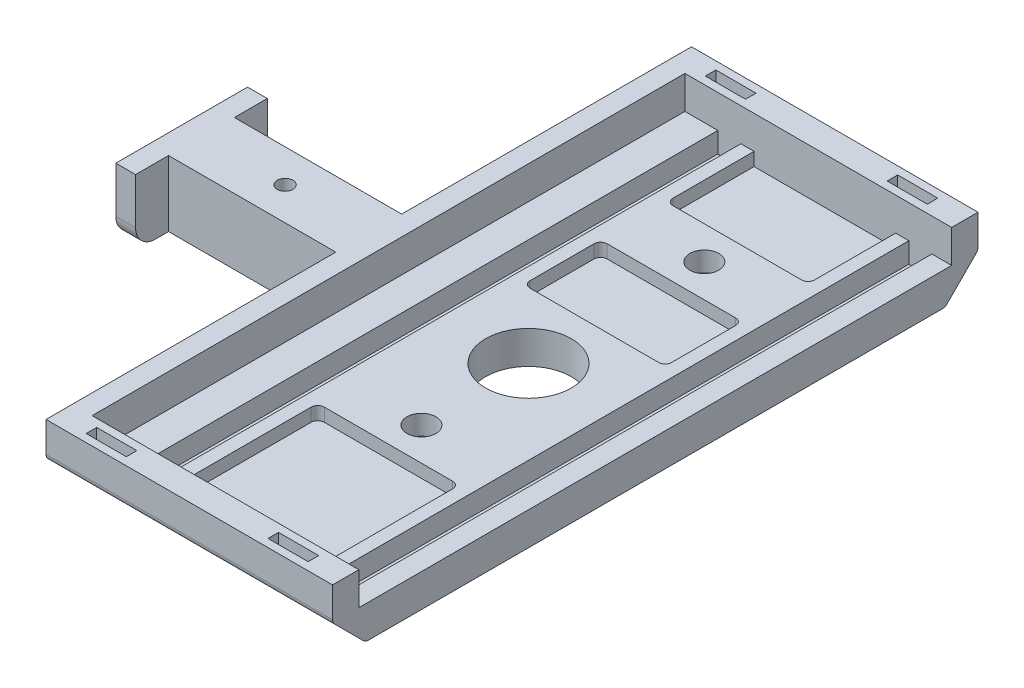
from build123d import *

# Parameters (mm, degrees)
BOSS_EXTRUDE1_DEPTH            = 45
SKETCH3_R                      = 6.5
CUT_EXTRUDE1_DEPTH             = 50.199212392
SKETCH5_W                      = 5
SKETCH5_H                      = 10
BOSS_EXTRUDE2_DEPTH            = 45
BOSS_EXTRUDE2_DEPTH_BACK       = 45
SKETCH8_W                      = 43.5
SKETCH8_H                      = 10
BOSS_EXTRUDE3_DEPTH            = 3
MOVE_FACE1_BY                  = 1
MOVE_FACE2_BY                  = 1
SKETCH10_W                     = 6.1
SKETCH10_H                     = 1.6
CUT_EXTRUDE2_DEPTH             = 3.5
CBORE_FOR_M2_SHCS1_D           = 2.4
CBORE_FOR_M2_SHCS1_CBORE_D     = 4.4
CBORE_FOR_M2_SHCS1_CBORE_DEPTH = 3
SKETCH12_W                     = 10
SKETCH12_H                     = 10
BOSS_EXTRUDE4_DEPTH            = 25.4
SKETCH13_W                     = 3
SKETCH13_H                     = 10
BOSS_EXTRUDE5_DEPTH            = 10
FILLET1_R                      = 3
CHAMFER1_SIZE                  = 5
FILLET2_R                      = 1
MOVE_FACE3_BY                  = 2
M2_CLEARANCE_HOLE1_D           = 2.4
SKETCH18_W                     = 21.5
SKETCH18_H                     = 23.75
SKETCH18_H_2                   = 11.7
SKETCH18_H_3                   = 13.3
CUT_EXTRUDE4_DEPTH             = 2
FILLET4_R                      = 1


with BuildPart() as part:
    # Sketch2 → Boss-Extrude1 (new, symmetric)
    with BuildSketch(Plane.XY):
        Polygon((-19.25, 0), (19.25, 0), (19.25, 5), (16.25, 5), (16.25, 1.9), (12.75, 1.9), (12.75, 5), (-12.75, 5), (-12.75, 1.9), (-16.25, 1.9), (-16.25, 5), (-19.25, 5), align=None)
    extrude(amount=BOSS_EXTRUDE1_DEPTH, both=True)

    # Sketch3 → Cut-Extrude1 (cut, through all)
    with BuildSketch(Plane.XZ):
        with Locations(Location((0, 0, 0), (0, 0, 270))):
            Circle(SKETCH3_R)
    extrude(amount=-CUT_EXTRUDE1_DEPTH, mode=Mode.SUBTRACT)

    # Sketch5 → Boss-Extrude2 (add, two sides)
    with BuildSketch(Plane.XY) as boss_extrude2_sk:
        with Locations((-21.75, 5)):
            Rectangle(SKETCH5_W, SKETCH5_H)
    extrude(amount=BOSS_EXTRUDE2_DEPTH)
    extrude(boss_extrude2_sk.sketch, amount=-BOSS_EXTRUDE2_DEPTH_BACK)

    # Sketch8 → Boss-Extrude3 (add)
    with BuildSketch(Plane.XY.offset(45)):
        with Locations((-2.5, 5)):
            Rectangle(SKETCH8_W, SKETCH8_H)
    boss_extrude3 = extrude(amount=BOSS_EXTRUDE3_DEPTH)

    # Mirror1: Boss-Extrude3 across plane
    add(boss_extrude3.mirror(Plane.XY))

    # Move Face1: a face moved outward by 1.0
    extrude(part.faces().sort_by_distance((-2.5, 5, -48))[0], amount=MOVE_FACE1_BY, dir=(0, 0, -1))

    # Move Face2: a face moved outward by 1.0
    extrude(part.faces().sort_by_distance((-2.5, 5, 48))[0], amount=MOVE_FACE2_BY, dir=(0, 0, 1))

    # Sketch10 → Cut-Extrude2 (cut)
    with BuildSketch(Plane(origin=(0, 10, 0), x_dir=(1, 0, 0), z_dir=(0, 1, 0))):
        with Locations((-16.3, 47)):
            Rectangle(SKETCH10_W, SKETCH10_H)
        with Locations((11.3, 47)):
            Rectangle(SKETCH10_W, SKETCH10_H)
        with Locations((-16.3, -47)):
            Rectangle(SKETCH10_W, SKETCH10_H)
        with Locations((11.3, -47)):
            Rectangle(SKETCH10_W, SKETCH10_H)
    extrude(amount=-CUT_EXTRUDE2_DEPTH, mode=Mode.SUBTRACT)

    # CBORE for M2 SHCS1 (through all)
    with Locations(Plane(origin=(0, 5, 0), x_dir=(1, 0, 0), z_dir=(0, 1, 0))):
        with Locations((0, 26.7), (0, -16.25)):
            CounterBoreHole(CBORE_FOR_M2_SHCS1_D / 2, CBORE_FOR_M2_SHCS1_CBORE_D / 2, CBORE_FOR_M2_SHCS1_CBORE_DEPTH)

    # Sketch12 → Boss-Extrude4 (add)
    with BuildSketch(Plane.ZY.offset(24.25)):
        with Locations((0, 5)):
            Rectangle(SKETCH12_W, SKETCH12_H)
    extrude(amount=BOSS_EXTRUDE4_DEPTH)

    # Sketch13 → Boss-Extrude5 (add, symmetric)
    with BuildSketch(Plane.XY):
        with Locations((-51.15, 5)):
            Rectangle(SKETCH13_W, SKETCH13_H)
    extrude(amount=BOSS_EXTRUDE5_DEPTH, both=True)

    # Fillet1
    fillet1_edges = [part.edges().sort_by_distance(p)[0] for p in [
        (-51.15, 0, -10),
        (-51.15, 0, 10),
    ]]
    fillet(fillet1_edges, radius=FILLET1_R)

    # Chamfer1
    chamfer1_edges = [part.edges().sort_by_distance(p)[0] for p in [
        (-2.5, 0, 49),
        (-2.5, 0, -49),
    ]]
    chamfer(chamfer1_edges, length=CHAMFER1_SIZE)

    # Fillet2
    fillet2_edges = [part.edges().sort_by_distance(p)[0] for p in [
        (-2.5, 0, 44),
        (-2.5, 0, -44),
        (-2.5, 5, -49),
        (-2.5, 5, 49),
    ]]
    fillet(fillet2_edges, radius=FILLET2_R)

    # Move Face3: a face moved inward by 2.0
    extrude(part.faces().sort_by_distance((-19.25, 7.5, 0))[0], amount=MOVE_FACE3_BY, dir=(-1, 0, 0), mode=Mode.SUBTRACT)

    # M2 Clearance Hole1 (through all)
    with Locations(Plane(origin=(0, 10, 0), x_dir=(1, 0, 0), z_dir=(0, 1, 0))):
        with Locations((-36.95, 0)):
            Hole(M2_CLEARANCE_HOLE1_D / 2)

    # Sketch18 → Cut-Extrude4 (cut)
    with BuildSketch(Plane(origin=(0, 5, 0), x_dir=(1, 0, 0), z_dir=(0, 1, 0))):
        with Locations((0, -33.125)):
            Rectangle(SKETCH18_W, SKETCH18_H)
        with Locations((0, 15.85)):
            Rectangle(SKETCH18_W, SKETCH18_H_2)
        with Locations((0, 38.35)):
            Rectangle(SKETCH18_W, SKETCH18_H_3)
    extrude(amount=-CUT_EXTRUDE4_DEPTH, mode=Mode.SUBTRACT)

    # Fillet4
    fillet4_edges = [part.edges().sort_by_distance(p)[0] for p in [
        (-10.75, 4, 21.25),
        (10.75, 4, 21.25),
        (-10.75, 4, -10),
        (-10.75, 4, -21.7),
        (10.75, 4, -21.7),
        (10.75, 4, -10),
        (-10.75, 4, -31.7),
        (10.75, 4, -31.7),
    ]]
    fillet(fillet4_edges, radius=FILLET4_R)


solid = part.part
